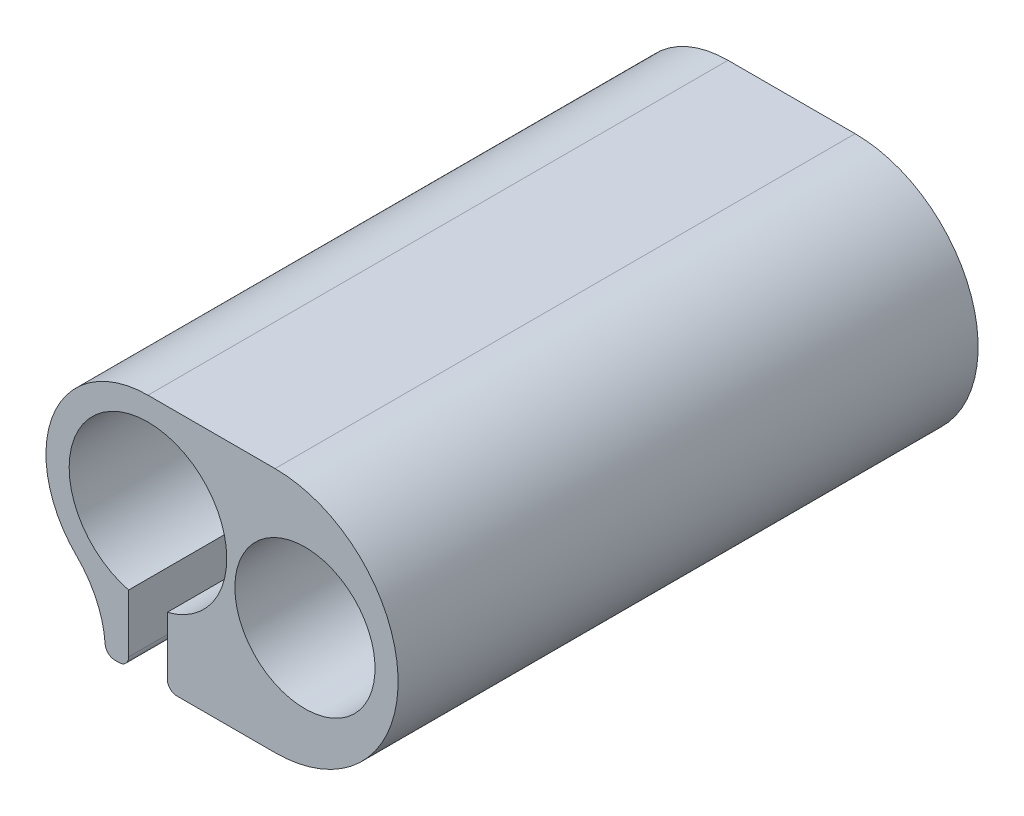
from build123d import *

# Parameters (mm, degrees)
BOSS_EXTRU_1_DEPTH      = 60
ESQUISSE2_R             = 7.25
ENL_V_MAT_EXTRU_1_DEPTH = 61
CONG_1_R                = 10
CONG_2_R                = 1


with BuildPart() as part:
    # Esquisse1 → Boss.-Extru.1 (new body)
    with BuildSketch(Plane.XY):
        with BuildLine():
            Line((-2, -7.9007911), (-2, -14.9007911))
            Line((-2, -14.9007911), (-4.4, -14.9007911))
            Line((-4.4, -14.9007911), (-4.4, -9.588665183))
            ThreePointArc((-4.4, -9.588665183), (-10.306864647, 2.251897235), (0, 10.55))
            Line((0, 10.55), (13.147142873, 10.55))
            ThreePointArc((13.147142873, 10.55), (25.872538423, -2.17539555), (13.147142873, -14.9007911))
            Line((13.147142873, -14.9007911), (4.4, -14.9007911))
            Line((4.4, -14.9007911), (2, -14.9007911))
            Line((2, -14.9007911), (2, -7.9007911))
            ThreePointArc((2, -7.9007911), (0, 8.15), (-2, -7.9007911))
        make_face()
    extrude(amount=BOSS_EXTRU_1_DEPTH)

    # Esquisse2 → Enlèv. mat.-Extru.1 (cut, through all)
    with BuildSketch(Plane(origin=(0, 0, 0), x_dir=(-1, 0, 0), z_dir=(0, 0, -1))):
        with Locations((-16.23903239, -2.17539555)):
            Circle(ESQUISSE2_R)
    extrude(amount=-ENL_V_MAT_EXTRU_1_DEPTH, mode=Mode.SUBTRACT)

    # Congé1
    cong_1_edges = [part.edges().sort_by_distance(p)[0] for p in [
        (-4.4, -9.588665183, 30),
    ]]
    fillet(cong_1_edges, radius=CONG_1_R)

    # Congé2
    cong_2_edges = [part.edges().sort_by_distance(p)[0] for p in [
        (-4.4, -14.9007911, 30),
        (-2, -14.9007911, 30),
        (2, -14.9007911, 30),
    ]]
    fillet(cong_2_edges, radius=CONG_2_R)


solid = part.part
